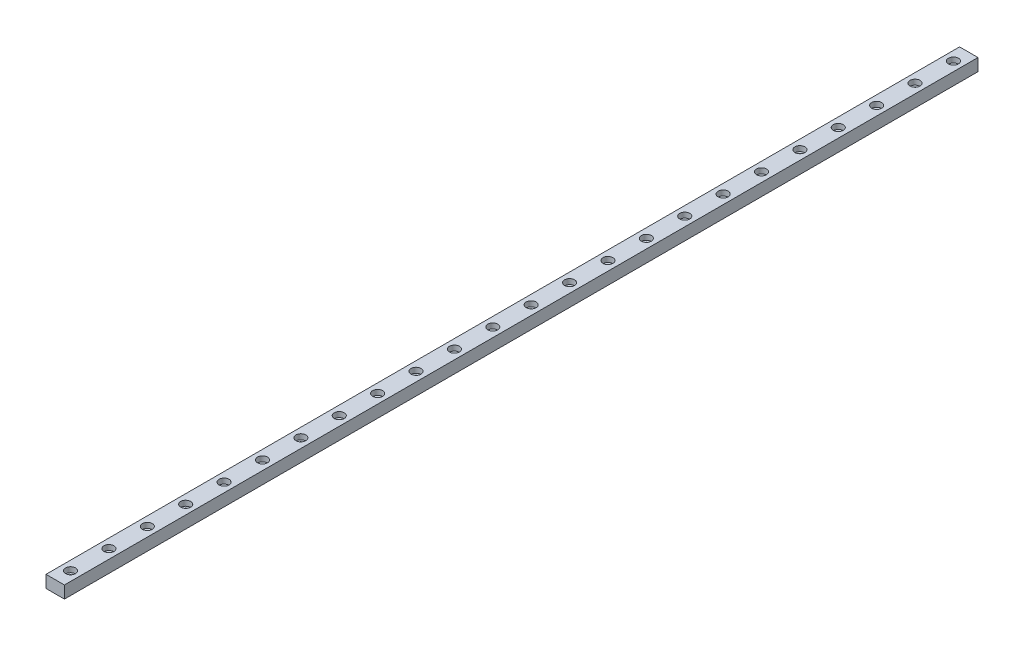
from build123d import *

# Parameters (mm, degrees)
SKETCH_1_W                   = 12
SKETCH_1_H                   = 8
EXTRUDE_1_DEPTH              = 595
HOLE_WIZARD_M3_1_D           = 3.4
HOLE_WIZARD_M3_1_CBORE_D     = 6.5
HOLE_WIZARD_M3_1_CBORE_DEPTH = 3.4
PATTERN_LINEAR_1_COUNT       = 24
PATTERN_LINEAR_1_PITCH       = 25


with BuildPart() as part:
    # 草图1 → 凸台-拉伸1 (new body)
    with BuildSketch(Plane.XY):
        with Locations((6, 4)):
            Rectangle(SKETCH_1_W, SKETCH_1_H)
    extrude(amount=EXTRUDE_1_DEPTH)

    # M3 六角凹头螺钉的柱形沉头孔1 (through all)
    with Locations(Plane(origin=(0, 8, 0), x_dir=(1, 0, 0), z_dir=(0, 1, 0))):
        with Locations((6, -585)):
            hole_wizard_m3_1 = CounterBoreHole(HOLE_WIZARD_M3_1_D / 2, HOLE_WIZARD_M3_1_CBORE_D / 2, HOLE_WIZARD_M3_1_CBORE_DEPTH)

    # 阵列(线性)1: M3 六角凹头螺钉的柱形沉头孔1 ×24
    with Locations(*[(0, 0, -i * PATTERN_LINEAR_1_PITCH) for i in range(1, PATTERN_LINEAR_1_COUNT)]):
        add(hole_wizard_m3_1, mode=Mode.SUBTRACT)


solid = part.part
